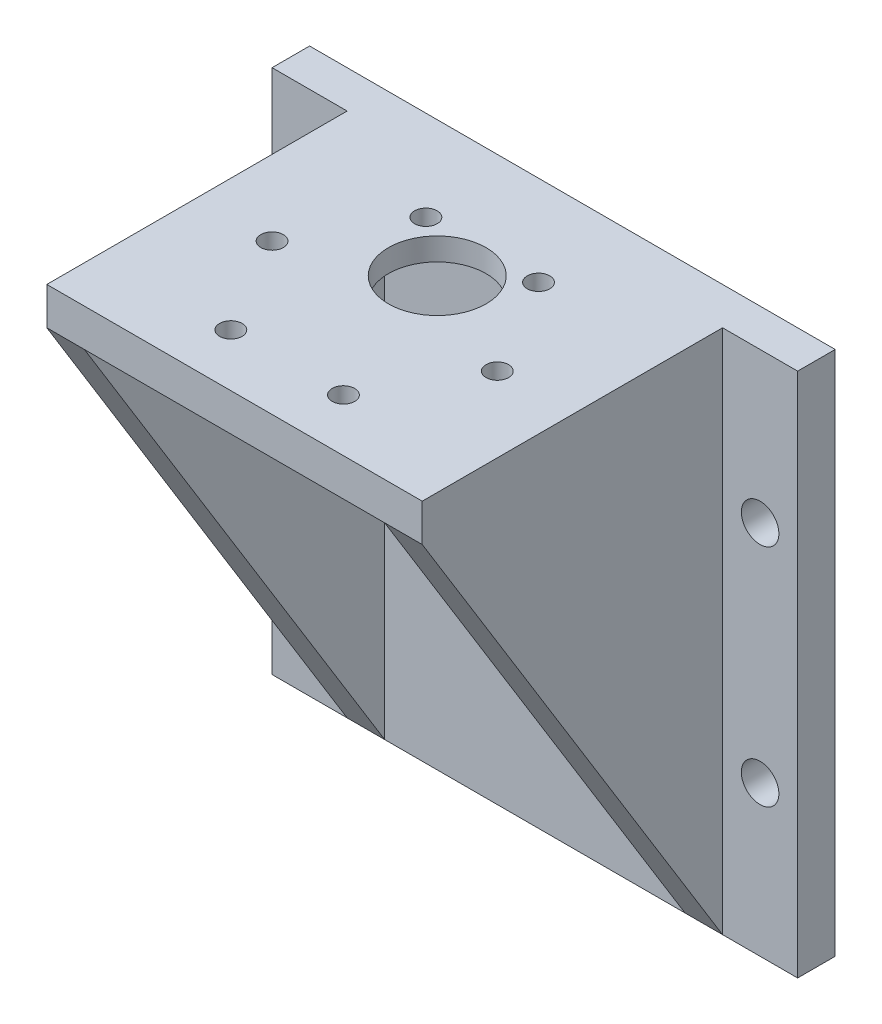
from build123d import *

# Parameters (mm, degrees)
ESQUISSE1_W                  = 70
ESQUISSE1_H                  = 70
BOSS_EXTRU_1_DEPTH           = 5
BOSS_EXTRU_2_DEPTH           = 40
ENL_V_MAT_EXTRU_1_DEPTH      = 50
ESQUISSE5_R                  = 2.5
ENL_V_MAT_EXTRU_2_DEPTH      = 5
ESQUISSE6_R                  = 19
ENL_V_MAT_EXTRU_3_DEPTH      = 2
ESQUISSE7_R                  = 6.5
ENL_V_MAT_EXTRU_4_DEPTH      = 3
ESQUISSE10_R                 = 1.5
ENL_V_MAT_EXTRU_5_DEPTH      = 3
R_P_TITION_CIRCULAIRE1_COUNT = 6


with BuildPart() as part:
    # Esquisse1 → Boss.-Extru.1 (new body)
    with BuildSketch(Plane.XY):
        with Locations((-11.714867345, -1.723076923)):
            Rectangle(ESQUISSE1_W, ESQUISSE1_H)
    extrude(amount=BOSS_EXTRU_1_DEPTH)

    # Esquisse3 → Boss.-Extru.2 (add)
    with BuildSketch(Plane.XY.offset(5)):
        Polygon((-36.714867345, -36.723076923), (-36.714867345, 33.276923077), (13.285132655, 33.276923077), (13.285132655, -36.723076923), (8.285132655, -36.723076923), (8.285132655, 28.276923077), (-31.714867345, 28.276923077), (-31.714867345, -36.723076923), align=None)
    extrude(amount=BOSS_EXTRU_2_DEPTH)

    # Esquisse4 → Enlèv. mat.-Extru.1 (cut)
    with BuildSketch(Plane.ZY.offset(36.714867345)):
        Polygon((45, 28.276923077), (5, -36.723076923), (45, -36.723076923), align=None)
    extrude(amount=-ENL_V_MAT_EXTRU_1_DEPTH, mode=Mode.SUBTRACT)

    # Esquisse5 → Enlèv. mat.-Extru.2 (cut)
    with BuildSketch(Plane.XY.offset(5)):
        with Locations((-41.714867345, 13.276923077)):
            Circle(ESQUISSE5_R)
        with Locations((-41.714867345, -16.723076923)):
            Circle(ESQUISSE5_R)
        with Locations((18.285132655, -16.723076923)):
            Circle(ESQUISSE5_R)
        with Locations((18.285132655, 13.276923077)):
            Circle(ESQUISSE5_R)
    extrude(amount=-ENL_V_MAT_EXTRU_2_DEPTH, mode=Mode.SUBTRACT)

    # Esquisse6 → Enlèv. mat.-Extru.3 (cut)
    with BuildSketch(Plane.XZ.offset(-28.276923077)):
        with Locations((-11.714867345, 25)):
            Circle(ESQUISSE6_R)
    extrude(amount=-ENL_V_MAT_EXTRU_3_DEPTH, mode=Mode.SUBTRACT)

    # Esquisse7 → Enlèv. mat.-Extru.4 (cut)
    with BuildSketch(Plane.XZ.offset(-30.276923077)):
        with Locations((-11.714867345, 18)):
            Circle(ESQUISSE7_R)
    extrude(amount=-ENL_V_MAT_EXTRU_4_DEPTH, mode=Mode.SUBTRACT)

    # Esquisse10 → Enlèv. mat.-Extru.5 (cut)
    with BuildSketch(Plane.XZ.offset(-30.276923077)):
        with Locations((-26.714867345, 25)):
            Circle(ESQUISSE10_R)
    enl_v_mat_extru_5 = extrude(amount=-ENL_V_MAT_EXTRU_5_DEPTH, mode=Mode.SUBTRACT)

    # Répétition circulaire1: Enlèv. mat.-Extru.5 ×6 about axis
    r_p_tition_circulaire1_axis = Axis((-11.714867345, 0, 25), (0, 1, 0))
    for i in range(1, R_P_TITION_CIRCULAIRE1_COUNT):
        add(enl_v_mat_extru_5.rotate(r_p_tition_circulaire1_axis, i * 360 / R_P_TITION_CIRCULAIRE1_COUNT), mode=Mode.SUBTRACT)


solid = part.part
